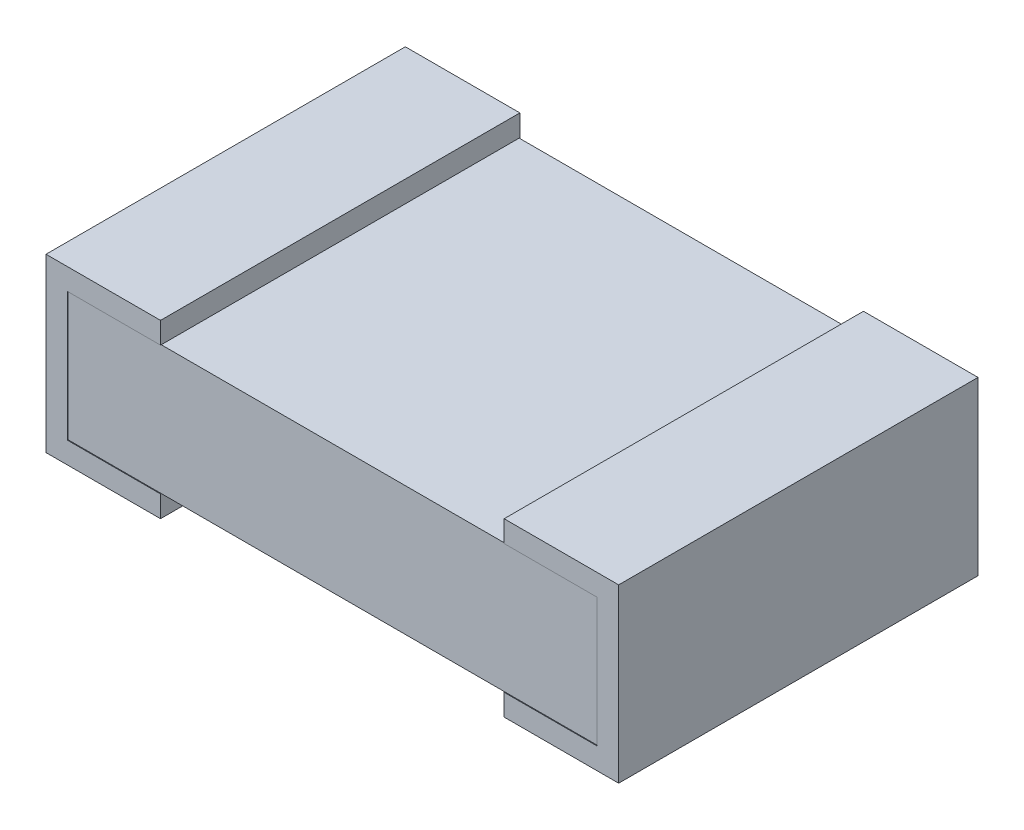
from build123d import *

# Parameters (mm, degrees)
SKETCH1_W           = 1.8796
SKETCH1_H           = 0.4572
BASE_EXTRUDE_DEPTH  = 0.635
BOSS_EXTRUDE1_DEPTH = 1.27508


with BuildPart() as part:
    # Sketch1 → Base-Extrude (new body, symmetric)
    with BuildSketch(Plane.XY):
        with Locations((1.016, 0.3048)):
            Rectangle(SKETCH1_W, SKETCH1_H)
    extrude(amount=BASE_EXTRUDE_DEPTH, both=True)

    # Sketch2 → Boss-Extrude1 (add)
    with BuildSketch(Plane(origin=(0, 0, -0.63754), x_dir=(-1, 0, 0), z_dir=(0, 0, -1))):
        Polygon((0, 0), (-0.4064, 0), (-0.4064, 0.0762), (-0.0762, 0.0762), (-0.0762, 0.5334), (-0.4064, 0.5334), (-0.4064, 0.6096), (0, 0.6096), align=None)
    boss_extrude1 = extrude(amount=-BOSS_EXTRUDE1_DEPTH)

    # Mirror1: Boss-Extrude1 across plane
    add(boss_extrude1.mirror(Plane(origin=(1.016, 0, 0), x_dir=(0, 0, 1), z_dir=(1, 0, 0))))


solid = part.part
